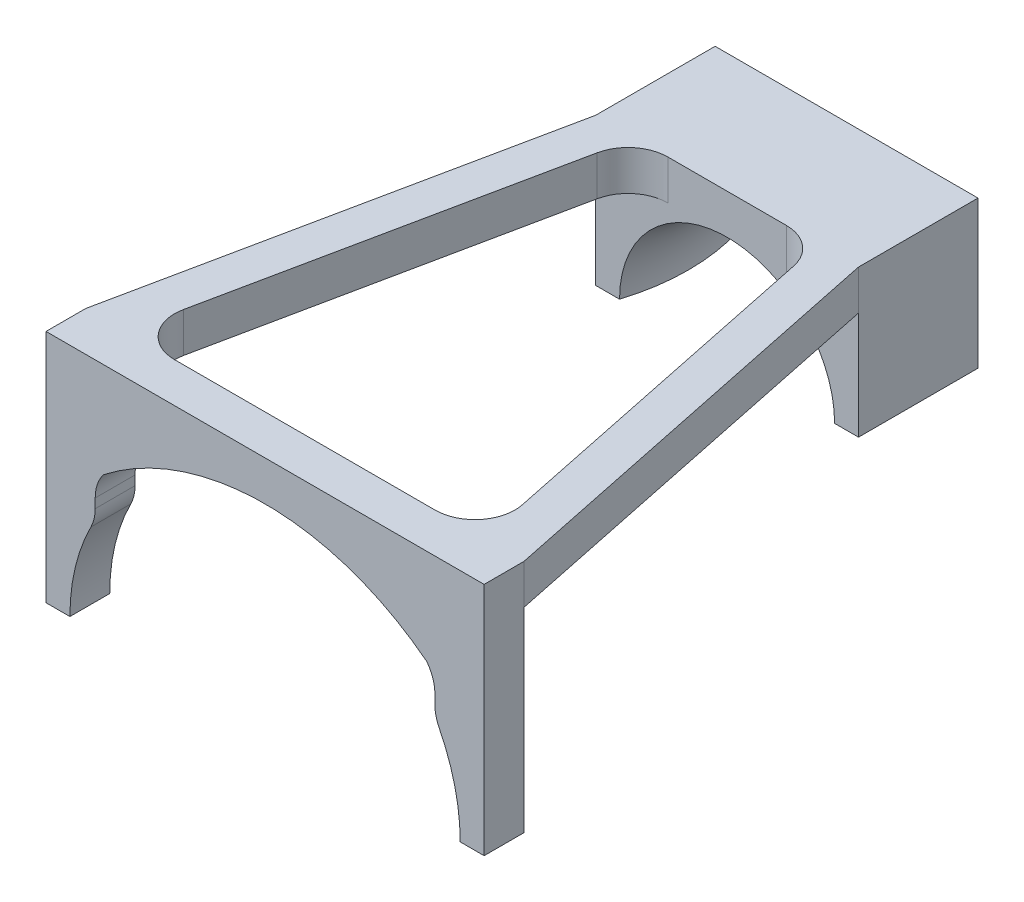
from build123d import *

# Parameters (mm, degrees)
BOSS_EXTRUDE1_DEPTH = 5
BOSS_EXTRUDE2_START = -53
BOSS_EXTRUDE2_DEPTH = 15
REVOLVE2_ANGLE      = 180
BOSS_EXTRUDE3_DEPTH = 5
FILLET1_R           = 5


with BuildPart() as part:
    # Sketch1 → Boss-Extrude1 (new body)
    with BuildSketch(Plane.XY):
        with BuildLine():
            Line((-21.323076923, 14.485250559), (-21.323076923, 13.317117605))
            ThreePointArc((-21.323076923, 13.317117605), (-21.459554932, 12.156878903), (-21.861538462, 11.059979028))
            ThreePointArc((-21.861538462, 11.059979028), (-23.831257754, 5.685169641), (-24.5, 0))
            Line((-24.5, 0), (-27.5, 0))
            Line((-27.5, 0), (-27.5, 29.5))
            Line((-27.5, 29.5), (27.5, 29.5))
            Line((27.5, 29.5), (27.5, 0))
            Line((27.5, 0), (24.5, 0))
            ThreePointArc((24.5, 0), (23.831257754, 5.685169641), (21.861538462, 11.059979028))
            ThreePointArc((21.861538462, 11.059979028), (21.459554932, 12.156878903), (21.323076923, 13.317117605))
            Line((21.323076923, 13.317117605), (21.323076923, 14.485250559))
            ThreePointArc((21.323076923, 14.485250559), (21.059553746, 16.08705807), (20.296762002, 17.52002022))
            ThreePointArc((20.296762002, 17.52002022), (10.731713115, 22.70625472), (0, 24.5))
            ThreePointArc((0, 24.5), (-10.731713115, 22.70625472), (-20.296762002, 17.52002022))
            ThreePointArc((-20.296762002, 17.52002022), (-21.059553746, 16.08705807), (-21.323076923, 14.485250559))
        make_face()
    extrude(amount=BOSS_EXTRUDE1_DEPTH)



with BuildPart() as body_2:
    # Sketch2 → Boss-Extrude2 (new body)
    with BuildSketch(Plane.XY.offset(BOSS_EXTRUDE2_START)):
        with BuildLine():
            Line((-16.5, 11), (-13.5, 11))
            ThreePointArc((-13.5, 11), (0, 24.5), (13.5, 11))
            Line((13.5, 11), (16.5, 11))
            Line((16.5, 11), (16.5, 29.5))
            Line((16.5, 29.5), (-16.5, 29.5))
            Line((-16.5, 29.5), (-16.5, 11))
        make_face()
    extrude(amount=-BOSS_EXTRUDE2_DEPTH)

    # Sketch5 → Revolve2 (revolve)
    with BuildSketch(Plane.XZ.offset(-11)):
        with BuildLine():
            Line((13.5, -53), (13.5, -68))
            ThreePointArc((13.5, -68), (12.348480035, -60.5), (13.5, -53))
        make_face()
    revolve(axis=Axis((0, 11, -60.5), (0, 0, 1)), revolution_arc=REVOLVE2_ANGLE)


with BuildPart() as part_1:
    add(part.part)

    add(body_2.part)  # Boss-Extrude3 merges body 2
    # Sketch6 → Boss-Extrude3 (add)
    with BuildSketch(Plane(origin=(0, 29.5, 0), x_dir=(1, 0, 0), z_dir=(0, 1, 0))):
        Polygon((-27.5, 0), (-16.5, 53), (-11.5, 53), (-22.5, 0), align=None)
        Polygon((22.5, 0), (11.5, 53), (16.5, 53), (27.5, 0), align=None)
    extrude(amount=-BOSS_EXTRUDE3_DEPTH)

    # Fillet1
    fillet1_edges = [part_1.edges().sort_by_distance(p)[0] for p in [
        (-22.5, 27, 0),
        (-11.5, 27, -53),
        (22.5, 27, 0),
        (11.5, 27, -53),
    ]]
    fillet(fillet1_edges, radius=FILLET1_R)


solid = part_1.part
